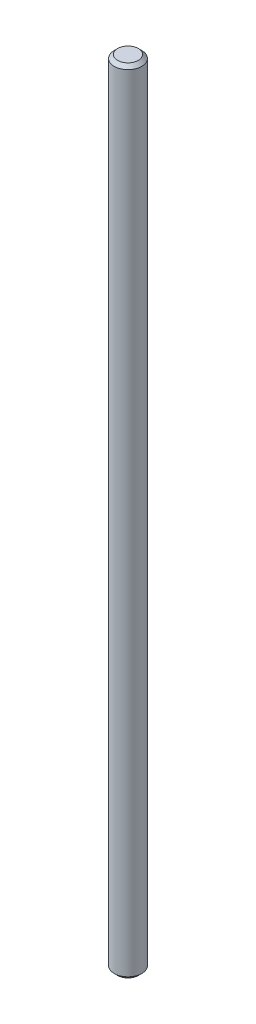
from build123d import *

# Parameters (mm, degrees)
SKETCH_1_R      = 4
EXTRUDE_1_DEPTH = 230
CHAMFER_1_SIZE  = 1


with BuildPart() as part:
    # 草图1 → 凸台-拉伸1 (new body)
    with BuildSketch(Plane(origin=(0, 0, 0), x_dir=(1, 0, 0), z_dir=(0, 1, 0))):
        Circle(SKETCH_1_R)
    extrude(amount=EXTRUDE_1_DEPTH)

    # 倒角1
    chamfer_1_edges = [part.edges().sort_by_distance(p)[0] for p in [
        (-4, 0, 0),
        (-4, 230, 0),
    ]]
    chamfer(chamfer_1_edges, length=CHAMFER_1_SIZE)


solid = part.part
